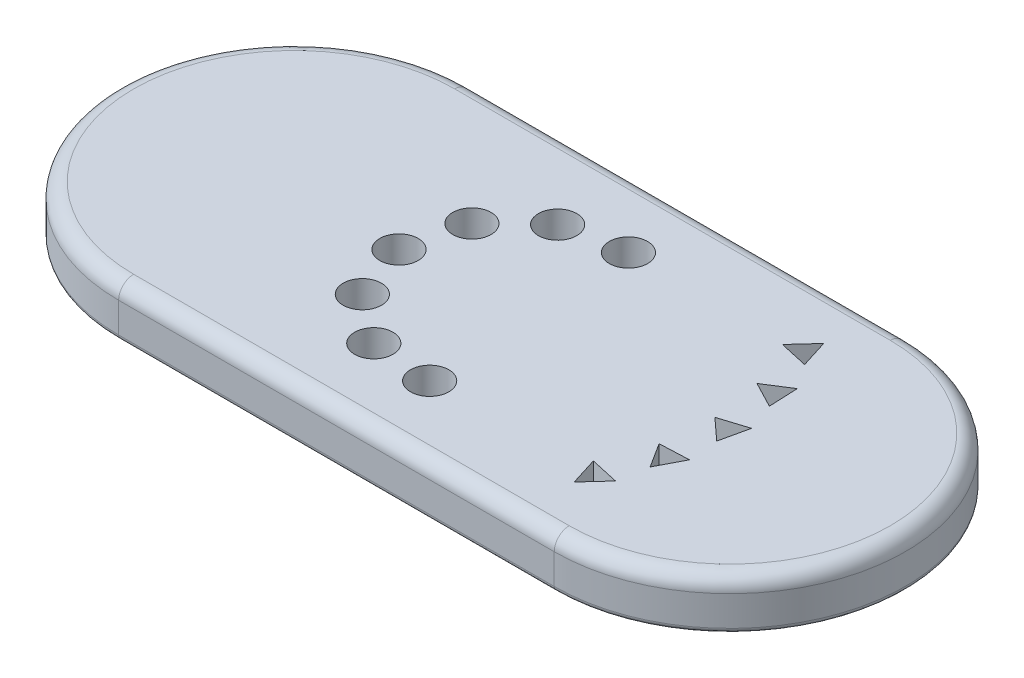
from build123d import *

# Parameters (mm, degrees)
BOSS_EXTRUDE1_DEPTH = 10
SKETCH2_R           = 3.829706391
CUT_EXTRUDE1_DEPTH  = 10
CIRPATTERN1_COUNT   = 7
CIRPATTERN1_ANGLE   = 198
CUT_EXTRUDE2_DEPTH  = 10
CIRPATTERN2_COUNT   = 5
CIRPATTERN2_ANGLE   = 60
FILLET1_R           = 3
FILLET2_R           = 1


with BuildPart() as part:
    # Sketch1 → Boss-Extrude1 (new body)
    with BuildSketch(Plane(origin=(0, 0, 0), x_dir=(1, 0, 0), z_dir=(0, 1, 0))):
        with BuildLine():
            Line((-45.667120744, 35.07764347), (41.365145602, 35.07764347))
            ThreePointArc((41.365145602, 35.07764347), (76.442789072, 0), (41.365145602, -35.07764347))
            Line((41.365145602, -35.07764347), (-45.667120744, -35.07764347))
            ThreePointArc((-45.667120744, -35.07764347), (-80.744764215, 0), (-45.667120744, 35.07764347))
        make_face()
    extrude(amount=BOSS_EXTRUDE1_DEPTH)

    # Sketch2 → Cut-Extrude1 (cut)
    with BuildSketch(Plane(origin=(0, 10, 0), x_dir=(1, 0, 0), z_dir=(0, 1, 0))):
        with Locations((0, 21.114814392)):
            Circle(SKETCH2_R)
    cut_extrude1 = extrude(amount=-CUT_EXTRUDE1_DEPTH, mode=Mode.SUBTRACT)

    # CirPattern1: Cut-Extrude1 ×7 about axis
    cirpattern1_axis = Axis((-2.160973251, 0, 0.098022779), (0, 1, 0))
    for i in range(1, CIRPATTERN1_COUNT):
        add(cut_extrude1.rotate(cirpattern1_axis, i * CIRPATTERN1_ANGLE / (CIRPATTERN1_COUNT - 1)), mode=Mode.SUBTRACT)

    # Sketch3 → Cut-Extrude2 (cut)
    with BuildSketch(Plane(origin=(0, 10, 0), x_dir=(1, 0, 0), z_dir=(0, 1, 0))):
        Polygon((36.992565085, 19.326531544), (35.239702282, 24.889438713), (31.298514755, 20.589961412), align=None)
    cut_extrude2 = extrude(amount=-CUT_EXTRUDE2_DEPTH, mode=Mode.SUBTRACT)

    # CirPattern2: Cut-Extrude2 ×5 about axis
    cirpattern2_axis = Axis((-1.883123212, 0, 0.01175113), (0, -1, 0))
    for i in range(1, CIRPATTERN2_COUNT):
        add(cut_extrude2.rotate(cirpattern2_axis, i * CIRPATTERN2_ANGLE / (CIRPATTERN2_COUNT - 1)), mode=Mode.SUBTRACT)

    # Fillet1
    fillet1_edges = [part.edges().sort_by_distance(p)[0] for p in [
        (76.442789072, 10, 0),
        (-2.150987571, 10, -35.07764347),
        (-80.744764215, 10, 0),
        (-2.150987571, 10, 35.07764347),
    ]]
    fillet(fillet1_edges, radius=FILLET1_R)

    # Fillet2
    fillet2_edges = [part.edges().sort_by_distance(p)[0] for p in [
        (-2.150987571, 0, -35.07764347),
        (76.442789072, 0, 0),
        (-2.150987571, 0, 35.07764347),
        (-80.744764215, 0, 0),
    ]]
    fillet(fillet2_edges, radius=FILLET2_R)


solid = part.part
